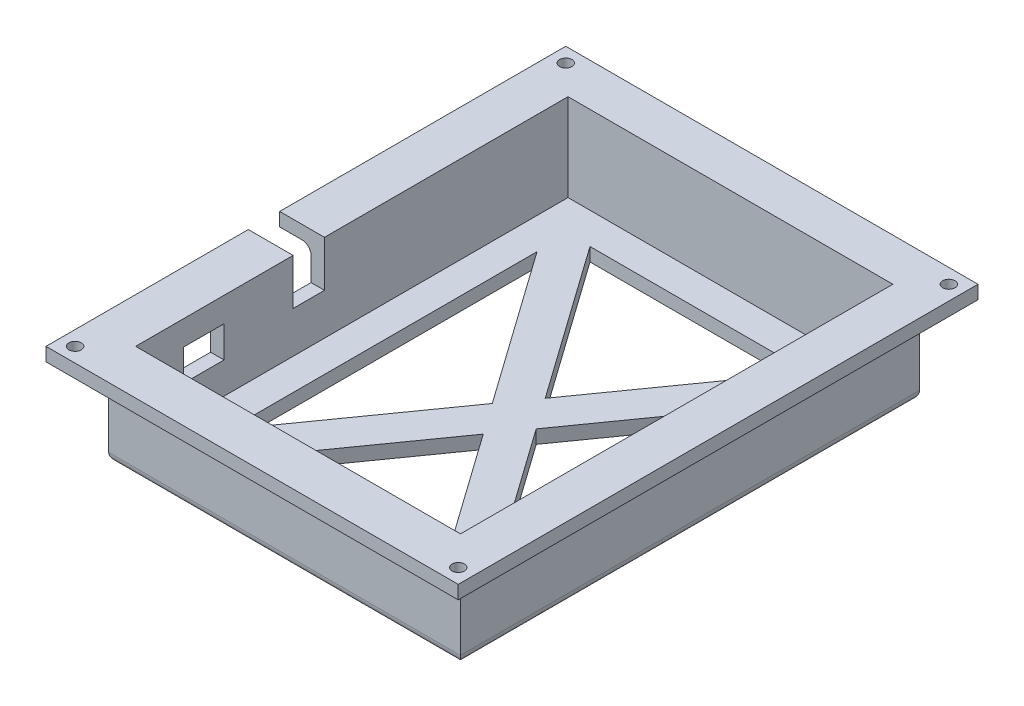
from build123d import *

# Parameters (mm, degrees)
SKETCH1_W              = 72.5
SKETCH1_H              = 96.5
BRACKETBASE_DEPTH      = 3
SKETCH3_W              = 78.5
SKETCH3_H              = 102.5
SKETCH3_W_2            = 72.5
SKETCH3_H_2            = 96.5
BRACKETWALLS_DEPTH     = 22.5
SKETCH4_W              = 7
SKETCH4_H              = 19.5
WIREHOLE_DEPTH         = 22.5
BRACKETFLANGE_DEPTH    = 3
SKETCH7_R              = 1.375
MOUNTINGHOLES_DEPTH    = 4
SKETCH8_W              = 9
SKETCH8_H              = 7
SWITCHHOLE_DEPTH       = 10
BOSS_EXTRUDE1_REACH    = 72.85
SKETCH10_W             = 2.5
SKETCH10_H             = 7
BOSS_EXTRUDE2_DEPTH    = 12.25
FILLET1_R              = 2
FILLET2_R              = 2
SKETCH11_W             = 7
SKETCH11_H             = 10.25
CUT_EXTRUDE1_DEPTH     = 10
WEIGHTREDUCTION1_DEPTH = 23.5


with BuildPart() as part:
    # Sketch1 → bracketBase (new body)
    with BuildSketch(Plane(origin=(0, 0, 0), x_dir=(1, 0, 0), z_dir=(0, 1, 0))):
        with Locations((36.25, 48.25)):
            Rectangle(SKETCH1_W, SKETCH1_H)
    extrude(amount=BRACKETBASE_DEPTH)

    # Sketch3 → bracketWalls (add)
    with BuildSketch(Plane.XZ):
        with Locations((36.25, -48.25)):
            Rectangle(SKETCH3_W, SKETCH3_H)
        with Locations((36.25, -48.25)):
            Rectangle(SKETCH3_W_2, SKETCH3_H_2, mode=Mode.SUBTRACT)
    extrude(amount=-BRACKETWALLS_DEPTH)

    # Sketch4 → wireHole (cut)
    with BuildSketch(Plane.ZY.offset(-72.5)):
        with Locations((-38.65, 12.75)):
            Rectangle(SKETCH4_W, SKETCH4_H)
    wirehole = extrude(amount=-WIREHOLE_DEPTH, mode=Mode.SUBTRACT)

    # Sketch6 → bracketFlange (add)
    with BuildSketch(Plane(origin=(0, 22.5, 0), x_dir=(1, 0, 0), z_dir=(0, 1, 0))):
        Polygon((72.5, 96.5), (72.5, 42.15), (82, 42.15), (82, 106), (-10, 106), (-10, -10), (82, -10), (82, 35.15), (72.5, 35.15), (72.5, 0), (0, 0), (0, 96.5), align=None)
    extrude(amount=-BRACKETFLANGE_DEPTH)

    # Sketch7 → mountingHoles (cut, through all)
    with BuildSketch(Plane.XZ.offset(-19.5)):
        with Locations((78.75, -102.75)):
            Circle(SKETCH7_R)
        with Locations((78.75, 6.75)):
            Circle(SKETCH7_R)
        with Locations((-6.75, -102.75)):
            Circle(SKETCH7_R)
        with Locations((-6.75, 6.75)):
            Circle(SKETCH7_R)
    extrude(amount=-MOUNTINGHOLES_DEPTH, mode=Mode.SUBTRACT)

    # Mirror1: wireHole across plane
    add(wirehole.mirror(Plane(origin=(36, 0, 0), x_dir=(0, 0, 1), z_dir=(1, 0, 0))), mode=Mode.SUBTRACT)

    # Sketch8 → switchHole (cut)
    with BuildSketch(Plane.ZY.offset(3)):
        with Locations((-15.23, 13.5)):
            Rectangle(SKETCH8_W, SKETCH8_H)
    extrude(amount=-SWITCHHOLE_DEPTH, mode=Mode.SUBTRACT)

    # Sketch9 → Boss-Extrude1 (add, up to next)
    with BuildSketch(Plane(origin=(0, 0, -35.15), x_dir=(-1, 0, 0), z_dir=(0, 0, -1)), mode=Mode.PRIVATE) as boss_extrude1_sk1:
        Polygon((-72.5, 3), (-72.5, 22.5), (-82, 22.5), (-82, 19.5), (-75.5, 19.5), (-75.5, 3), align=None)
    boss_extrude1_tool1 = extrude(boss_extrude1_sk1.sketch, amount=BOSS_EXTRUDE1_REACH, mode=Mode.PRIVATE) - part.part
    add(boss_extrude1_tool1.solids().sort_by_distance((75.1875, 14.8125, -35.15))[0])

    # Sketch10 → Boss-Extrude2 (add)
    with BuildSketch(Plane.XZ):
        with Locations((-1.75, -38.65)):
            Rectangle(SKETCH10_W, SKETCH10_H)
    extrude(amount=-BOSS_EXTRUDE2_DEPTH)

    # Fillet1
    fillet1_edges = [part.edges().sort_by_distance(p)[0] for p in [
        (-3, 19.5, -16.075),
        (36.25, 19.5, 3),
        (75.5, 19.5, -48.25),
        (36.25, 19.5, -99.5),
        (-3, 19.5, -70.825),
    ]]
    fillet(fillet1_edges, radius=FILLET1_R)

    # Fillet2
    fillet2_edges = [part.edges().sort_by_distance(p)[0] for p in [
        (36.25, 0, 3),
        (-3, 0, -48.25),
        (36.25, 0, -99.5),
        (75.5, 0, -48.25),
    ]]
    fillet(fillet2_edges, radius=FILLET2_R)

    # Sketch11 → Cut-Extrude1 (cut)
    with BuildSketch(Plane.ZY.offset(0.5)):
        with Locations((-38.65, 17.375)):
            Rectangle(SKETCH11_W, SKETCH11_H)
    extrude(amount=-CUT_EXTRUDE1_DEPTH, mode=Mode.SUBTRACT)

    # Sketch12 → weightReduction1 (cut, through all)
    with BuildSketch(Plane.XZ):
        Polygon((11.903565914, -89.5), (36.25, -55.165285264), (60.596434086, -89.5), align=None)
        Polygon((65.5, -82.584714736), (41.153565914, -48.25), (65.5, -13.915285264), align=None)
        Polygon((60.596434086, -7), (11.903565914, -7), (36.25, -41.334714736), align=None)
        Polygon((7, -13.915285264), (7, -82.584714736), (31.346434086, -48.25), align=None)
    extrude(amount=-WEIGHTREDUCTION1_DEPTH, mode=Mode.SUBTRACT)


solid = part.part
